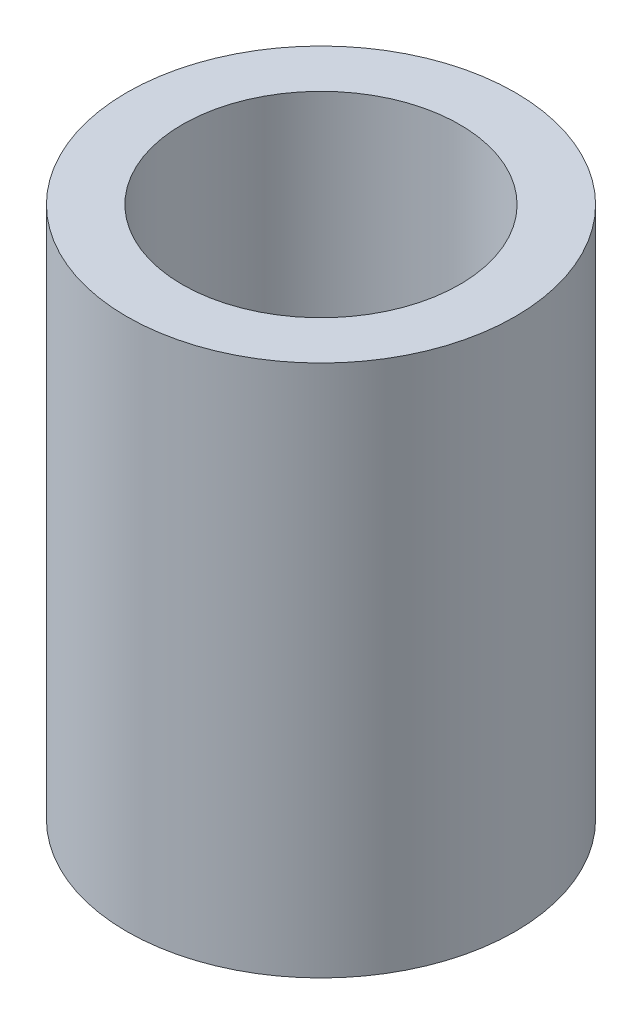
from build123d import *

# Parameters (mm, degrees)
SKETCH1_R           = 3.5
SKETCH1_R_2         = 2.5
BOSS_EXTRUDE1_DEPTH = 9.6


with BuildPart() as part:
    # Sketch1 → Boss-Extrude1 (new body)
    with BuildSketch(Plane(origin=(0, 0, 0), x_dir=(1, 0, 0), z_dir=(0, 1, 0))):
        Circle(SKETCH1_R)
        Circle(SKETCH1_R_2, mode=Mode.SUBTRACT)
    extrude(amount=BOSS_EXTRUDE1_DEPTH)


solid = part.part
